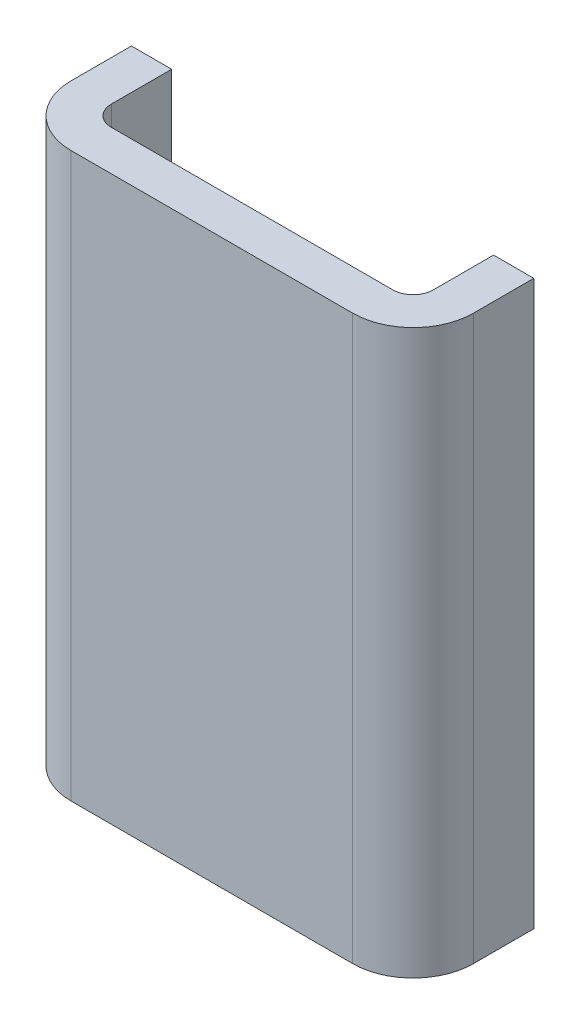
from build123d import *

# Parameters (mm, degrees)
SKETCH2_W           = 50.8
SKETCH2_H           = 12.7
BOSS_EXTRUDE1_DEPTH = 88.9
FILLET2_R           = 3.175
SHELL1_T            = 6.35


with BuildPart() as part:
    # Sketch2 → Boss-Extrude1 (new body)
    with BuildSketch(Plane(origin=(0, 0, 0), x_dir=(1, 0, 0), z_dir=(0, 1, 0))):
        with Locations((25.4, 6.35)):
            Rectangle(SKETCH2_W, SKETCH2_H)
    extrude(amount=BOSS_EXTRUDE1_DEPTH)

    # Fillet2
    fillet2_edges = [part.edges().sort_by_distance(p)[0] for p in [
        (50.8, 44.45, 0),
        (0, 44.45, 0),
    ]]
    fillet(fillet2_edges, radius=FILLET2_R)

    # Shell1
    shell1_openings = [part.faces().sort_by_distance(p)[0] for p in [
        (25.4, 0, -6.38808439),
        (25.4, 88.9, -6.38808439),
        (25.4, 44.45, -12.7),
    ]]
    offset(amount=SHELL1_T, openings=shell1_openings, kind=Kind.INTERSECTION)


solid = part.part
